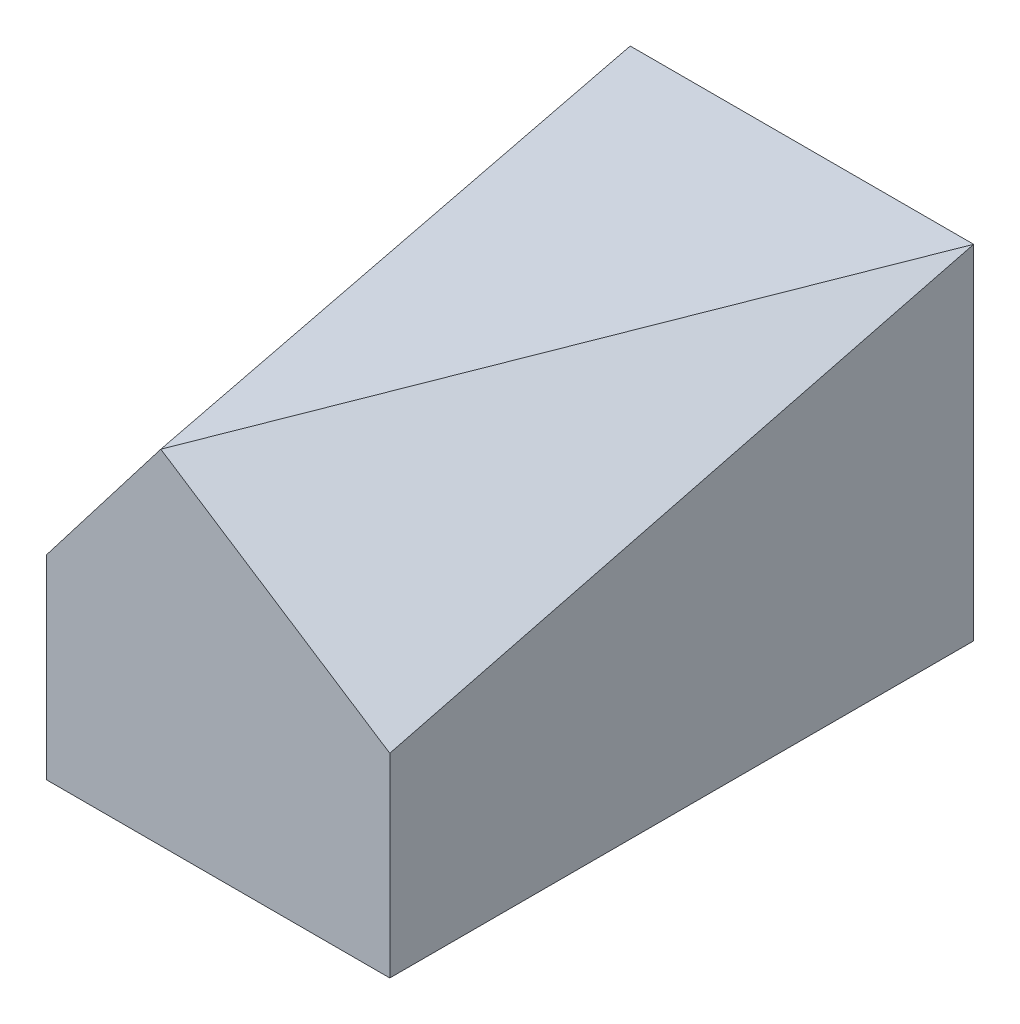
from build123d import *

# Parameters (mm, degrees)
SKETCH2_W           = 30
SKETCH2_H           = 51
BOSS_EXTRUDE1_DEPTH = 30


with BuildPart() as part:
    # Sketch2 → Boss-Extrude1 (new body)
    with BuildSketch(Plane(origin=(0, 0, 0), x_dir=(1, 0, 0), z_dir=(0, 1, 0))):
        with Locations((15, 25.5)):
            Rectangle(SKETCH2_W, SKETCH2_H)
    extrude(amount=BOSS_EXTRUDE1_DEPTH)

    # SurfaceCut2
    split(bisect_by=Plane(origin=(15.949847794, 24.538227375, 6.254842272), x_dir=(0.8461451498623624, -0.5164387356010117, -0.1316412463296696), z_dir=(0.5329525169885216, 0.8199269492131106, 0.20900098705432213)), keep=Keep.BOTTOM)

    # SurfaceCut3
    split(bisect_by=Plane(origin=(-8.02185135, 6.170654885, 1.572912029), x_dir=(-0.1217254970638359, 0.09363499774141223, -0.9881373338572569), z_dir=(0.7832213553451228, -0.6024779656500949, -0.15357281477355358)), keep=Keep.TOP)


solid = part.part
